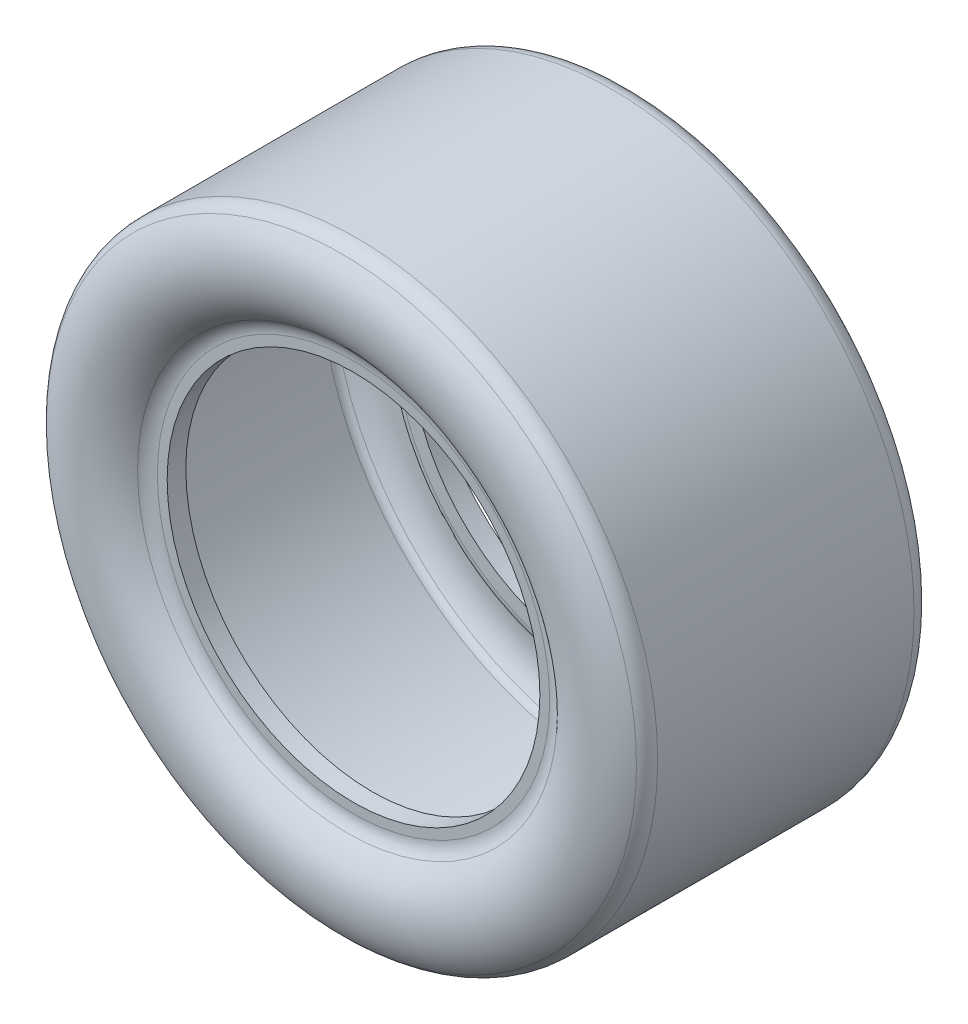
from build123d import *

# Parameters (mm, degrees)
FILLET1_R = 12.7


with BuildPart() as part:
    # Sketch1 → Revolve1 (revolve)
    with BuildSketch(Plane(origin=(0, 0, 0), x_dir=(0, 0, -1), z_dir=(1, 0, 0))):
        with BuildLine():
            Line((-92.71, 205.74), (92.71, 205.74))
            ThreePointArc((92.71, 205.74), (106.68, 171.804134615), (88.9, 139.7))
            Line((88.9, 139.7), (88.9, 127))
            Line((88.9, 127), (76.2, 127))
            Line((76.2, 127), (76.2, 136.77458415))
            ThreePointArc((76.2, 136.77458415), (77.341702115, 140.875929948), (80.438371617, 143.797429404))
            ThreePointArc((80.438371617, 143.797429404), (98.03590274, 166.972484114), (91.58192014, 195.346810028))
            ThreePointArc((91.58192014, 195.346810028), (89.358537587, 197.155629346), (86.566259724, 197.8025))
            Line((86.566259724, 197.8025), (-86.566259724, 197.8025))
            ThreePointArc((-86.566259724, 197.8025), (-89.358537587, 197.155629346), (-91.58192014, 195.346810028))
            ThreePointArc((-91.58192014, 195.346810028), (-98.03590274, 166.972484114), (-80.438371617, 143.797429404))
            ThreePointArc((-80.438371617, 143.797429404), (-77.341702115, 140.875929948), (-76.2, 136.77458415))
            Line((-76.2, 136.77458415), (-76.2, 127))
            Line((-76.2, 127), (-88.9, 127))
            Line((-88.9, 127), (-88.9, 139.7))
            ThreePointArc((-88.9, 139.7), (-106.68, 171.804134615), (-92.71, 205.74))
        make_face()
    revolve(axis=Axis((0, 0, 0), (0, 0, 1)))

    # Fillet1
    fillet1_edges = [part.edges().sort_by_distance(p)[0] for p in [
        (0, -205.74, 92.71),
        (0, -205.74, -92.71),
        (0, -139.7, -88.9),
        (0, -139.7, 88.9),
    ]]
    fillet(fillet1_edges, radius=FILLET1_R)


solid = part.part
